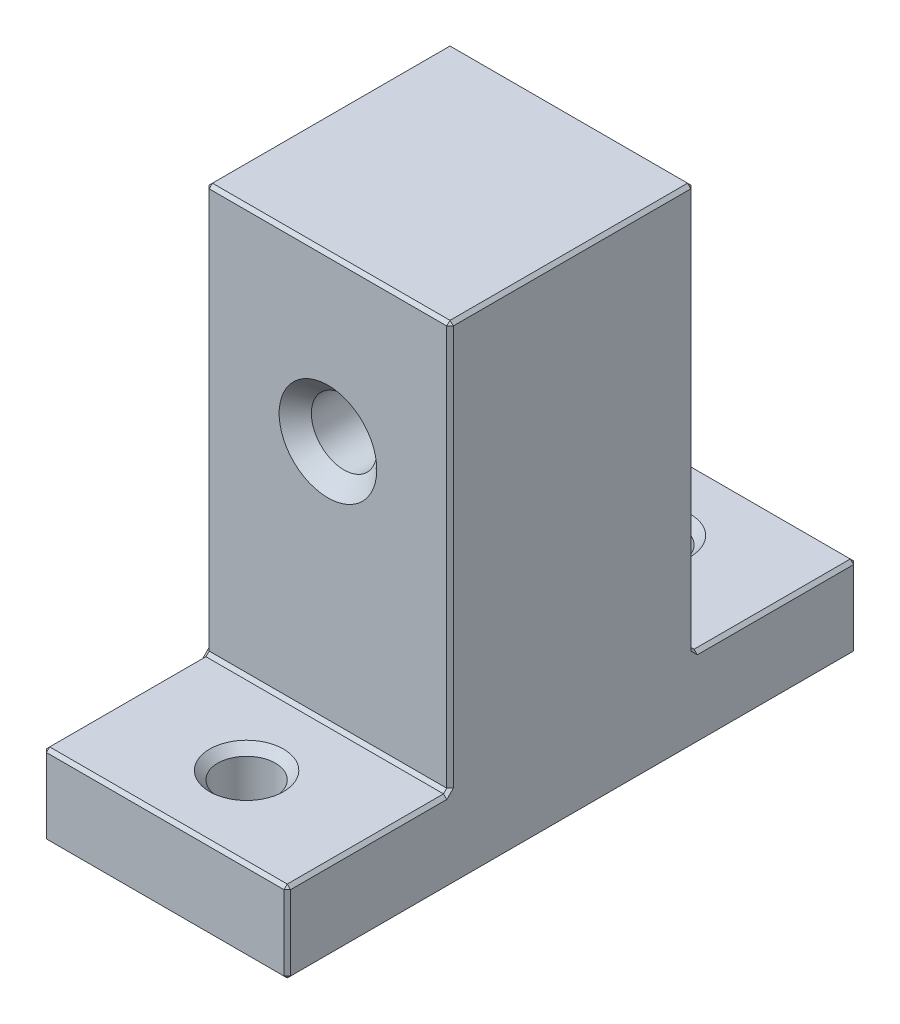
from build123d import *

# Parameters (mm, degrees)
SKETCH1_W                      = 19.05
SKETCH1_H                      = 44.45
SKETCH1_H_2                    = 19.05
BOSS_EXTRUDE1_DEPTH            = 6.35
SKETCH1_3_W                    = 19.05
SKETCH1_3_H                    = 19.05
BOSS_EXTRUDE2_DEPTH            = 38.1
F_8_CLEARANCE_HOLE1_AT_2_COUNT = 2
F_8_CLEARANCE_HOLE1_AT_2_PITCH = 31.75
CHAMFER1_SIZE                  = 0.254


with BuildPart() as part:
    # Sketch1 → Boss-Extrude1 (new body)
    with BuildSketch(Plane(origin=(0, 0, 0), x_dir=(1, 0, 0), z_dir=(0, 1, 0))):
        Rectangle(SKETCH1_W, SKETCH1_H)
        Rectangle(SKETCH1_W, SKETCH1_H_2)
    extrude(amount=BOSS_EXTRUDE1_DEPTH)

    # Sketch1_3 → Boss-Extrude2 (add)
    with BuildSketch(Plane(origin=(0, 0, 0), x_dir=(1, 0, 0), z_dir=(0, 1, 0))):
        Rectangle(SKETCH1_3_W, SKETCH1_3_H)
    extrude(amount=BOSS_EXTRUDE2_DEPTH)

    # Sketch4 → 1_4-20 Tapped Hole1 (revolve, cut)
    with BuildSketch(Plane(origin=(0, 25.4, 9.525), x_dir=(0, -1, 0), z_dir=(1, 0, 0))):
        Polygon((0, 0), (0, 19.05), (3.81, 19.05), (2.5527, 17.7927), (2.5527, 1.2573), (3.81, 0), align=None)
    revolve(axis=Axis((0, 25.4, 15.875), (0, 0, -1)), mode=Mode.SUBTRACT)

    # Sketch8 → 8 Clearance Hole1 (revolve, cut)
    with BuildSketch(Plane(origin=(0, 6.35, -15.875), x_dir=(0, 0, 1), z_dir=(1, 0, 0))):
        Polygon((0, 0), (0, 6.35), (2.8829, 6.35), (2.2479, 5.715), (2.2479, 0.635), (2.8829, 0), align=None)
    f_8_clearance_hole1 = revolve(axis=Axis((0, 12.7, -15.875), (0, -1, 0)), mode=Mode.SUBTRACT)

    # 8 Clearance Hole1 at 2: 8 Clearance Hole1 ×2
    with Locations(*[(0, 0, i * F_8_CLEARANCE_HOLE1_AT_2_PITCH) for i in range(1, F_8_CLEARANCE_HOLE1_AT_2_COUNT)]):
        add(f_8_clearance_hole1, mode=Mode.SUBTRACT)

    # Chamfer1
    chamfer1_edges = [part.edges().sort_by_distance(p)[0] for p in [
        (0, 6.35, -22.225),
        (-9.525, 6.35, 15.875),
        (9.525, 6.35, -15.875),
        (-9.525, 6.35, -15.875),
        (0, 6.35, 22.225),
        (0, 6.35, 9.525),
        (9.525, 22.225, -9.525),
        (0, 6.35, -9.525),
        (0, 38.1, -9.525),
        (-9.525, 22.225, -9.525),
        (-9.525, 38.1, 0),
        (-9.525, 22.225, 9.525),
        (9.525, 22.225, 9.525),
        (0, 38.1, 9.525),
        (9.525, 38.1, 0),
        (9.525, 6.35, 15.875),
        (0, 0, 22.225),
        (-9.525, 0, 0),
        (0, 0, -22.225),
        (9.525, 0, 0),
        (9.525, 3.175, 22.225),
        (-9.525, 3.175, 22.225),
        (-9.525, 3.175, -22.225),
        (9.525, 3.175, -22.225),
    ]]
    chamfer(chamfer1_edges, length=CHAMFER1_SIZE)


solid = part.part
